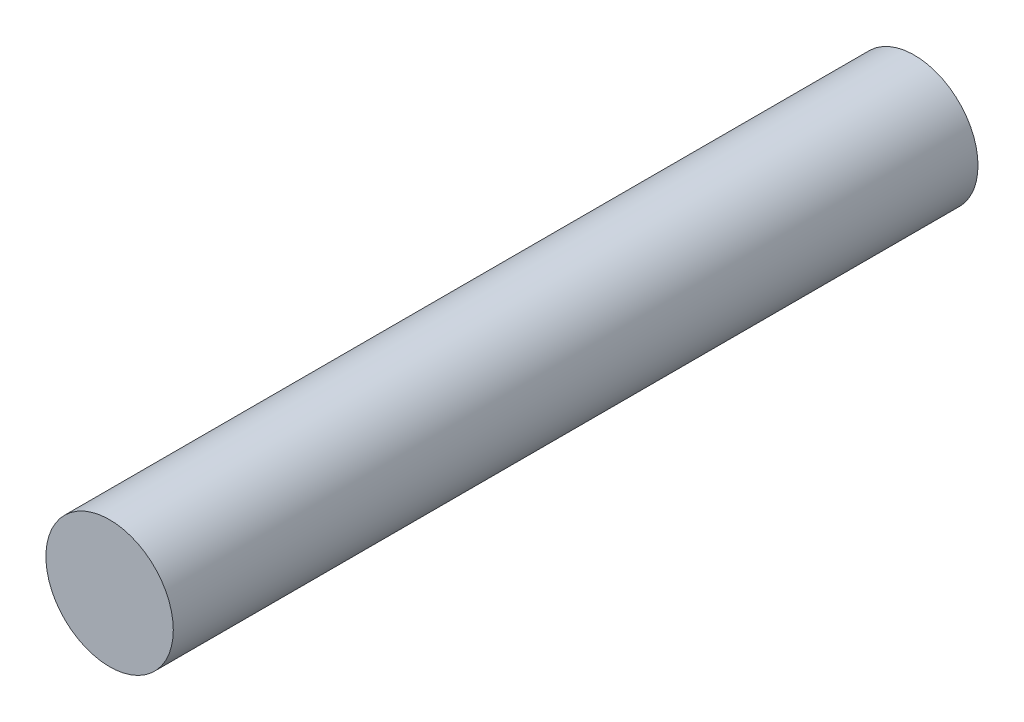
from build123d import *

# Parameters (mm, degrees)
SKETCH1_R           = 3.8
BOSS_EXTRUDE1_DEPTH = 48


with BuildPart() as part:
    # Sketch1 → Boss-Extrude1 (new body)
    with BuildSketch(Plane.XY):
        with Locations((-3.742722086, -2.1520652)):
            Circle(SKETCH1_R)
    extrude(amount=BOSS_EXTRUDE1_DEPTH)


solid = part.part
